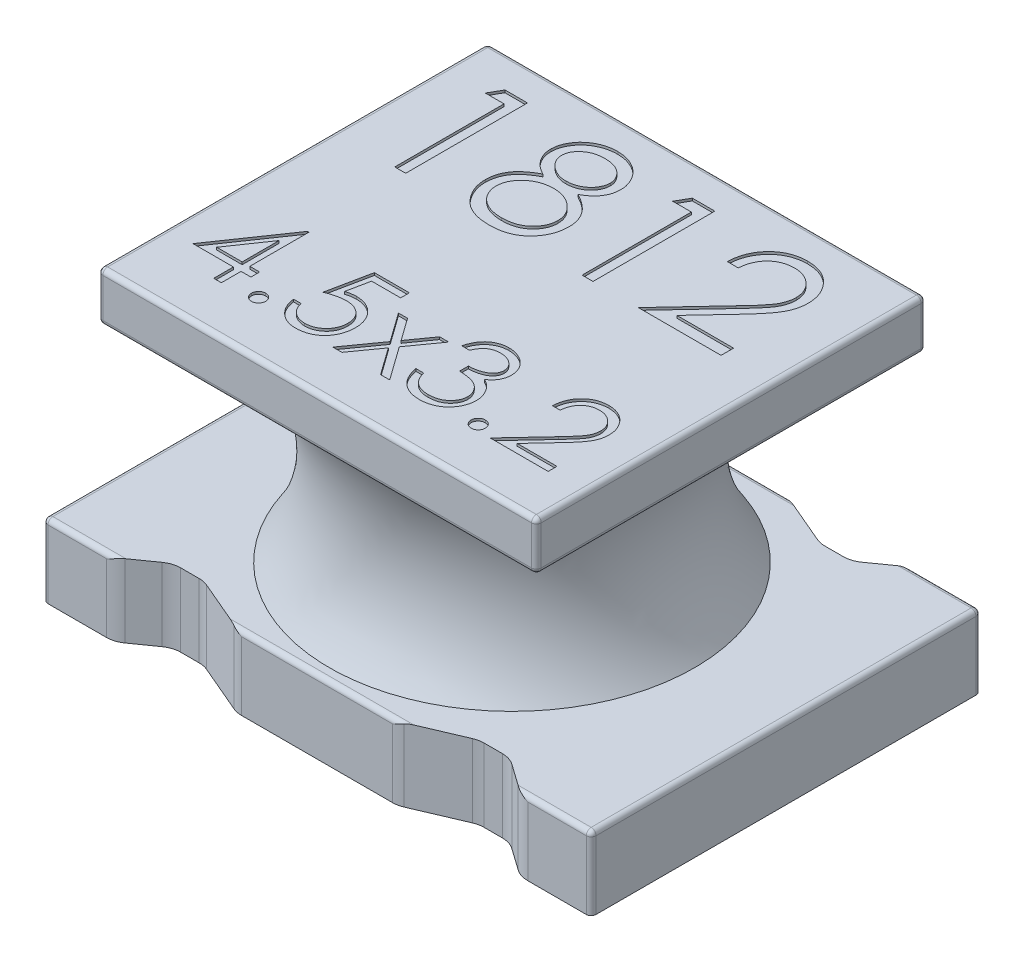
from build123d import *

# Parameters (mm, degrees)
SKETCH1_W           = 4.5
SKETCH1_H           = 3.2
BOSS_EXTRUDE1_DEPTH = 2.6
SKETCH4_W           = 1
SKETCH4_H           = 3.5
CUT_EXTRUDE2_DEPTH  = 1.5
FILLET1_R           = 0.04
CUT_EXTRUDE3_DEPTH  = 1
CUT_EXTRUDE4_DEPTH  = 0.02
CUT_EXTRUDE5_DEPTH  = 0.02


with BuildPart() as part:
    # Sketch1 → Boss-Extrude1 (new body)
    with BuildSketch(Plane(origin=(0, 0, 0), x_dir=(1, 0, 0), z_dir=(0, 1, 0))):
        Rectangle(SKETCH1_W, SKETCH1_H)
    extrude(amount=BOSS_EXTRUDE1_DEPTH)

    # Sketch3 → Cut-Revolve1 (revolve, cut)
    with BuildSketch(Plane(origin=(0, 0, 0), x_dir=(0, 0, -1), z_dir=(1, 0, 0))):
        with BuildLine():
            Line((3.2, 2.2), (3.2, 0.6))
            Line((3.2, 0.6), (1.5, 0.6))
            ThreePointArc((1.5, 0.6), (1.248912529, 1.4), (1.5, 2.2))
            Line((1.5, 2.2), (3.2, 2.2))
        make_face()
    revolve(axis=Axis((0, 0, 0), (0, 1, 0)), mode=Mode.SUBTRACT)

    # Sketch4 → Cut-Extrude2 (cut)
    with BuildSketch(Plane(origin=(0, 2.6, 0), x_dir=(1, 0, 0), z_dir=(0, 1, 0))):
        with Locations((2.3, 0)):
            Rectangle(SKETCH4_W, SKETCH4_H)
        with Locations((-2.3, 0)):
            Rectangle(SKETCH4_W, SKETCH4_H)
    extrude(amount=-CUT_EXTRUDE2_DEPTH, mode=Mode.SUBTRACT)

    # Fillet1
    fillet1_edges = [part.edges().sort_by_distance(p)[0] for p in [
        (-2.25, 0.3, -1.6),
        (2.25, 0.3, -1.6),
        (0, 0.6, -1.6),
        (2.25, 0.3, 1.6),
        (-2.25, 0.3, 1.6),
        (0, 0.6, 1.6),
        (-2.25, 0.6, 0),
        (2.25, 0.6, 0),
        (0, 2.2, -1.6),
        (1.8, 2.2, 0),
        (0, 2.6, -1.6),
        (1.8, 2.6, 0),
        (1.8, 2.4, 1.6),
        (1.8, 2.4, -1.6),
        (0, 2.2, 1.6),
        (-1.8, 2.2, 0),
        (0, 2.6, 1.6),
        (-1.8, 2.6, 0),
        (-1.8, 2.4, 1.6),
        (-1.8, 2.4, -1.6),
    ]]
    fillet(fillet1_edges, radius=FILLET1_R)

    # Sketch5 → Cut-Extrude3 (cut)
    with BuildSketch(Plane.XZ):
        with BuildLine():
            Line((-1.614539572, 1.563306122), (-1.435460428, 1.436693878))
            ThreePointArc((-1.435460428, 1.436693878), (-1.380575472, 1.409394092), (-1.32, 1.4))
            Line((-1.32, 1.4), (-1.17, 1.4))
            ThreePointArc((-1.17, 1.4), (-1.129898015, 1.404061666), (-1.091424839, 1.416081692))
            Line((-1.091424839, 1.416081692), (-0.698575161, 1.583918308))
            ThreePointArc((-0.698575161, 1.583918308), (-0.660101985, 1.595938334), (-0.62, 1.6))
            Line((-0.62, 1.6), (-0.5, 1.6))
            Line((-0.5, 1.6), (-0.5, 1.9))
            Line((-0.5, 1.9), (-1.85, 1.9))
            Line((-1.85, 1.9), (-1.85, 1.6))
            Line((-1.85, 1.6), (-1.73, 1.6))
            ThreePointArc((-1.73, 1.6), (-1.669424528, 1.590605908), (-1.614539572, 1.563306122))
        make_face()
        with BuildLine():
            Line((-0.5, -1.6), (-0.62, -1.6))
            ThreePointArc((-0.62, -1.6), (-0.660101985, -1.595938334), (-0.698575161, -1.583918308))
            Line((-0.698575161, -1.583918308), (-1.091424839, -1.416081692))
            ThreePointArc((-1.091424839, -1.416081692), (-1.129898015, -1.404061666), (-1.17, -1.4))
            Line((-1.17, -1.4), (-1.32, -1.4))
            ThreePointArc((-1.32, -1.4), (-1.380575472, -1.409394092), (-1.435460428, -1.436693878))
            Line((-1.435460428, -1.436693878), (-1.614539572, -1.563306122))
            ThreePointArc((-1.614539572, -1.563306122), (-1.669424528, -1.590605908), (-1.73, -1.6))
            Line((-1.73, -1.6), (-1.85, -1.6))
            Line((-1.85, -1.6), (-1.85, -1.9))
            Line((-1.85, -1.9), (-0.5, -1.9))
            Line((-0.5, -1.9), (-0.5, -1.6))
        make_face()
        with BuildLine():
            Line((1.614539572, -1.563306122), (1.435460428, -1.436693878))
            ThreePointArc((1.435460428, -1.436693878), (1.380575472, -1.409394092), (1.32, -1.4))
            Line((1.32, -1.4), (1.17, -1.4))
            ThreePointArc((1.17, -1.4), (1.129898015, -1.404061666), (1.091424839, -1.416081692))
            Line((1.091424839, -1.416081692), (0.698575161, -1.583918308))
            ThreePointArc((0.698575161, -1.583918308), (0.660101985, -1.595938334), (0.62, -1.6))
            Line((0.62, -1.6), (0.5, -1.6))
            Line((0.5, -1.6), (0.5, -1.9))
            Line((0.5, -1.9), (1.85, -1.9))
            Line((1.85, -1.9), (1.85, -1.6))
            Line((1.85, -1.6), (1.73, -1.6))
            ThreePointArc((1.73, -1.6), (1.669424528, -1.590605908), (1.614539572, -1.563306122))
        make_face()
        with BuildLine():
            Line((0.5, 1.6), (0.62, 1.6))
            ThreePointArc((0.62, 1.6), (0.660101985, 1.595938334), (0.698575161, 1.583918308))
            Line((0.698575161, 1.583918308), (1.091424839, 1.416081692))
            ThreePointArc((1.091424839, 1.416081692), (1.129898015, 1.404061666), (1.17, 1.4))
            Line((1.17, 1.4), (1.32, 1.4))
            ThreePointArc((1.32, 1.4), (1.380575472, 1.409394092), (1.435460428, 1.436693878))
            Line((1.435460428, 1.436693878), (1.614539572, 1.563306122))
            ThreePointArc((1.614539572, 1.563306122), (1.669424528, 1.590605908), (1.73, 1.6))
            Line((1.73, 1.6), (1.85, 1.6))
            Line((1.85, 1.6), (1.85, 1.9))
            Line((1.85, 1.9), (0.5, 1.9))
            Line((0.5, 1.9), (0.5, 1.6))
        make_face()
    extrude(amount=-CUT_EXTRUDE3_DEPTH, mode=Mode.SUBTRACT)

    # Sketch6 → Cut-Extrude4 (cut)
    with BuildSketch(Plane(origin=(0, 2.6, 0), x_dir=(1, 0, 0), z_dir=(0, 1, 0))):
        Polygon((-1.387573864, 1.32963938), (-1.202678031, 1.32963938), (-1.202678031, 0.32963938), (-1.29242162, 0.32963938), (-1.29242162, 1.227075277), (-1.446267774, 1.227075277), align=None)
        with BuildLine():
            add(Edge.make_bspline(
                [(-0.344705274, 0.886730726), (-0.336519975, 0.882462738), (-0.320555908, 0.874138738), (-0.297819563, 0.860735644), (-0.277040991, 0.846609654), (-0.257643688, 0.83242798), (-0.239968445, 0.817647508), (-0.224212898, 0.802209463), (-0.209987864, 0.786499193), (-0.197580211, 0.770250668), (-0.186666829, 0.753507054), (-0.177234791, 0.736224404), (-0.169172733, 0.718440595), (-0.162783322, 0.6999615), (-0.157519953, 0.681058568), (-0.153898351, 0.661487716), (-0.15195066, 0.641377905), (-0.151582428, 0.627786961), (-0.151395979, 0.620905405)],
                knots=[0, 0, 0, 0, 1.272397273, 2.481599622, 3.635517121, 4.734568067, 5.792894095, 6.808321871, 7.773003508, 8.711915296, 9.623354172, 10.525449501, 11.423591555, 12.311487226, 13.218079475, 14.126165749, 15.051214107, 16, 16, 16, 16], degree=3))
            add(Edge.make_bspline(
                [(-0.151395979, 0.620905405), (-0.151616385, 0.611277482), (-0.152052651, 0.592220208), (-0.155852647, 0.564092748), (-0.161542069, 0.536775096), (-0.169850501, 0.510273241), (-0.180625756, 0.484733421), (-0.193904852, 0.460133771), (-0.208936625, 0.436071111), (-0.221008693, 0.421265568), (-0.227117133, 0.413773995)],
                knots=[0, 0, 0, 0, 1.025265484, 2.029385089, 3.018602448, 3.995076438, 4.983346944, 5.966715145, 6.97116228, 8, 8, 8, 8], degree=3))
            add(Edge.make_bspline(
                [(-0.227117133, 0.413773995), (-0.235070412, 0.405032917), (-0.250878688, 0.387658776), (-0.277959524, 0.365101402), (-0.307680062, 0.346144432), (-0.3399253, 0.330695319), (-0.374609043, 0.318670788), (-0.411723902, 0.310030069), (-0.451342231, 0.305080803), (-0.478572366, 0.304365378), (-0.492541813, 0.303998354)],
                knots=[0, 0, 0, 0, 0.954267603, 1.896743057, 2.838368354, 3.796610408, 4.779680527, 5.799409237, 6.871065594, 8, 8, 8, 8], degree=3))
            add(Edge.make_bspline(
                [(-0.492541813, 0.303998354), (-0.505974209, 0.304327634), (-0.532112289, 0.304968378), (-0.570157397, 0.309309644), (-0.605621131, 0.316917606), (-0.638709694, 0.327330351), (-0.669223606, 0.340876131), (-0.697075921, 0.357735676), (-0.722668484, 0.377230374), (-0.745224619, 0.399920111), (-0.765249889, 0.42422236), (-0.782840761, 0.449294248), (-0.797461927, 0.475138065), (-0.809841097, 0.501368455), (-0.819317675, 0.528353071), (-0.825881163, 0.555953075), (-0.830049539, 0.584120258), (-0.830604149, 0.603129302), (-0.830883159, 0.612692264)],
                knots=[0, 0, 0, 0, 1.256902934, 2.445805442, 3.576955095, 4.645999104, 5.686449165, 6.692658513, 7.68621702, 8.689161843, 9.678783111, 10.630372946, 11.551080876, 12.453998257, 13.34127905, 14.221779781, 15.105423033, 16, 16, 16, 16], degree=3))
            add(Edge.make_bspline(
                [(-0.830883159, 0.612692264), (-0.83071805, 0.619709176), (-0.830391737, 0.633577071), (-0.828133209, 0.654065451), (-0.82450222, 0.674007203), (-0.819570946, 0.693475987), (-0.812887796, 0.712330065), (-0.804818615, 0.730658772), (-0.795409486, 0.7484828), (-0.784529153, 0.765899623), (-0.771871432, 0.782665198), (-0.75753896, 0.799064054), (-0.741245284, 0.81484173), (-0.723171667, 0.830190995), (-0.703524655, 0.84538413), (-0.681793932, 0.859600052), (-0.65855557, 0.873845185), (-0.64203974, 0.88236185), (-0.633567454, 0.886730726)],
                knots=[0, 0, 0, 0, 0.941657376, 1.861047343, 2.762797495, 3.66048619, 4.553285746, 5.444104102, 6.34607688, 7.256116206, 8.197091036, 9.162375105, 10.176350973, 11.237807142, 12.343728897, 13.50695164, 14.721116704, 16, 16, 16, 16], degree=3))
            add(Edge.make_bspline(
                [(-0.633567454, 0.886730726), (-0.645164989, 0.893054945), (-0.667621064, 0.905300405), (-0.697355191, 0.927799492), (-0.722895369, 0.952167439), (-0.743539574, 0.978918809), (-0.759788782, 1.007217916), (-0.770936954, 1.036887703), (-0.778478807, 1.067378021), (-0.7792259, 1.088208363), (-0.779601108, 1.098669828)],
                knots=[0, 0, 0, 0, 1.166880483, 2.259407225, 3.286803203, 4.280235371, 5.237608625, 6.161067461, 7.076446754, 8, 8, 8, 8], degree=3))
            add(Edge.make_bspline(
                [(-0.779601108, 1.098669828), (-0.779133844, 1.109326274), (-0.778194561, 1.130747587), (-0.770599327, 1.162635051), (-0.758222165, 1.193954069), (-0.741387595, 1.224552845), (-0.720419818, 1.253395763), (-0.695263663, 1.279264605), (-0.666519863, 1.301925028), (-0.634331901, 1.320946792), (-0.599692977, 1.336427837), (-0.563145627, 1.347107387), (-0.525326629, 1.354089134), (-0.499584424, 1.354879607), (-0.486532197, 1.355280405)],
                knots=[0, 0, 0, 0, 0.888701115, 1.786444228, 2.72001202, 3.692817113, 4.693886446, 5.687152267, 6.695133018, 7.739871481, 8.800368666, 9.853104506, 10.91144658, 12, 12, 12, 12], degree=3))
            add(Edge.make_bspline(
                [(-0.486532197, 1.355280405), (-0.473816822, 1.354867164), (-0.448743549, 1.354052301), (-0.411887941, 1.34725605), (-0.376623691, 1.335904758), (-0.343072405, 1.320505552), (-0.311834729, 1.301537854), (-0.284234069, 1.278566176), (-0.259853331, 1.252811447), (-0.239686362, 1.223977275), (-0.223068393, 1.193496077), (-0.211496707, 1.161603928), (-0.204081857, 1.128989911), (-0.203146611, 1.10692191), (-0.202678031, 1.095865341)],
                knots=[0, 0, 0, 0, 1.072916533, 2.115669174, 3.151510826, 4.193348718, 5.225979165, 6.227137561, 7.216255879, 8.211077061, 9.189680878, 10.138522389, 11.067357538, 12, 12, 12, 12], degree=3))
            add(Edge.make_bspline(
                [(-0.202678031, 1.095865341), (-0.203087905, 1.085014866), (-0.203892875, 1.063705149), (-0.210664287, 1.032640429), (-0.22206809, 1.003548418), (-0.237637851, 0.976099003), (-0.257930848, 0.950790003), (-0.2826762, 0.927299583), (-0.311676622, 0.905434775), (-0.333465447, 0.893095814), (-0.344705274, 0.886730726)],
                knots=[0, 0, 0, 0, 0.975232327, 1.915300861, 2.843280834, 3.77672583, 4.742871857, 5.749627742, 6.839139064, 8, 8, 8, 8], degree=3))
        make_face()
        with BuildLine():
            add(Edge.make_bspline(
                [(-0.49154021, 1.252716303), (-0.498554726, 1.252530177), (-0.512278186, 1.252166033), (-0.532400664, 1.250263566), (-0.551535626, 1.246562647), (-0.569882998, 1.2416373), (-0.58719123, 1.234983589), (-0.603695388, 1.227156444), (-0.619114585, 1.217640425), (-0.633634958, 1.206965797), (-0.646706607, 1.195224967), (-0.658307908, 1.182992476), (-0.667944512, 1.170028078), (-0.676127686, 1.156654261), (-0.682065262, 1.142474096), (-0.686512206, 1.127922332), (-0.689518318, 1.112815079), (-0.689743573, 1.102490362), (-0.689857518, 1.097267585)],
                knots=[0, 0, 0, 0, 1.203892937, 2.355340988, 3.463153438, 4.544400666, 5.610487187, 6.640501085, 7.674077295, 8.714426146, 9.728707835, 10.68524104, 11.601827946, 12.495867327, 13.368432065, 14.231010473, 15.105153427, 16, 16, 16, 16], degree=3))
            add(Edge.make_bspline(
                [(-0.689857518, 1.097267585), (-0.689661127, 1.092044582), (-0.689273031, 1.081723178), (-0.686271566, 1.066481502), (-0.681798179, 1.051503892), (-0.674755133, 1.037146489), (-0.666307602, 1.022911243), (-0.655881466, 1.009153933), (-0.64345603, 0.99582668), (-0.629448189, 0.98304284), (-0.61418775, 0.971071765), (-0.598020881, 0.960679427), (-0.581150483, 0.951983967), (-0.563749892, 0.944746994), (-0.545641764, 0.939121298), (-0.526937057, 0.935130256), (-0.507632628, 0.932649685), (-0.494552462, 0.932353394), (-0.487934441, 0.932203482)],
                knots=[0, 0, 0, 0, 0.873023192, 1.725219244, 2.590779336, 3.480155217, 4.391973325, 5.357036234, 6.360879153, 7.436073238, 8.526419356, 9.601555421, 10.645666583, 11.697338044, 12.750135903, 13.812665442, 14.89329948, 16, 16, 16, 16], degree=3))
            add(Edge.make_bspline(
                [(-0.487934441, 0.932203482), (-0.479434411, 0.932452873), (-0.462518306, 0.932949191), (-0.437581354, 0.937563812), (-0.413334885, 0.944822646), (-0.390038055, 0.954754065), (-0.368293887, 0.967219167), (-0.348911011, 0.982142887), (-0.332054756, 0.999180629), (-0.317900296, 1.018067153), (-0.306926054, 1.038167607), (-0.29838268, 1.058339119), (-0.293393762, 1.0787969), (-0.292743028, 1.092501746), (-0.29242162, 1.09927079)],
                knots=[0, 0, 0, 0, 1.076279235, 2.141928126, 3.20205304, 4.278698113, 5.344010996, 6.36967002, 7.368914609, 8.37248503, 9.349703398, 10.264243087, 11.142681841, 12, 12, 12, 12], degree=3))
            add(Edge.make_bspline(
                [(-0.29242162, 1.09927079), (-0.292573591, 1.104021657), (-0.292875231, 1.113451448), (-0.295360962, 1.127376695), (-0.299468342, 1.140985148), (-0.305029222, 1.154389225), (-0.312346307, 1.167400863), (-0.321021789, 1.180224602), (-0.331560218, 1.192571964), (-0.34338777, 1.204730692), (-0.356800744, 1.21598327), (-0.37177329, 1.225878901), (-0.388228648, 1.234282432), (-0.406167205, 1.24110779), (-0.425522897, 1.246234176), (-0.446206576, 1.250073132), (-0.468390704, 1.252236879), (-0.483656347, 1.252553029), (-0.49154021, 1.252716303)],
                knots=[0, 0, 0, 0, 0.814439003, 1.616544685, 2.417341072, 3.248991801, 4.09997495, 4.973547432, 5.9003056, 6.880240646, 7.880314356, 8.896779544, 9.951930927, 11.043077905, 12.18215768, 13.381699519, 14.647792085, 16, 16, 16, 16], degree=3))
        make_face(mode=Mode.SUBTRACT)
        with BuildLine():
            add(Edge.make_bspline(
                [(-0.485730915, 0.82963938), (-0.494623997, 0.829481196), (-0.512070053, 0.82917088), (-0.537629175, 0.825716737), (-0.562158651, 0.820908339), (-0.585575776, 0.813613813), (-0.607870661, 0.804129102), (-0.629163999, 0.792719233), (-0.649292893, 0.779231964), (-0.667979386, 0.763838645), (-0.685043194, 0.74725023), (-0.700014137, 0.72968962), (-0.712727715, 0.711483182), (-0.722965786, 0.692399688), (-0.731369138, 0.672843227), (-0.736887389, 0.652326771), (-0.740425021, 0.631244739), (-0.740900058, 0.616913282), (-0.741139569, 0.609687457)],
                knots=[0, 0, 0, 0, 1.140299081, 2.23698856, 3.303958914, 4.344563908, 5.37730929, 6.408454204, 7.439741482, 8.480804886, 9.510774543, 10.48932336, 11.43758569, 12.353841022, 13.263987381, 14.161954604, 15.073269652, 16, 16, 16, 16], degree=3))
            add(Edge.make_bspline(
                [(-0.741139569, 0.609687457), (-0.740750067, 0.600707198), (-0.739977303, 0.582890574), (-0.733846835, 0.556558268), (-0.72400811, 0.531066538), (-0.71028662, 0.506623123), (-0.693295885, 0.483780235), (-0.672402608, 0.463869157), (-0.648905226, 0.446177306), (-0.622008696, 0.431868582), (-0.592629135, 0.42044148), (-0.560774355, 0.412568348), (-0.526901521, 0.407356505), (-0.503513066, 0.406831311), (-0.49154021, 0.406562457)],
                knots=[0, 0, 0, 0, 0.898778495, 1.783155532, 2.693654817, 3.627872908, 4.583023416, 5.533784346, 6.509005473, 7.520592997, 8.575161974, 9.658835044, 10.801527049, 12, 12, 12, 12], degree=3))
            add(Edge.make_bspline(
                [(-0.49154021, 0.406562457), (-0.482182962, 0.406742116), (-0.463952043, 0.407092151), (-0.437356057, 0.410181949), (-0.412257615, 0.415081842), (-0.388705387, 0.422208569), (-0.366435718, 0.430908562), (-0.345826188, 0.442100586), (-0.326346609, 0.454829821), (-0.30895686, 0.469932151), (-0.2931188, 0.48606915), (-0.279309288, 0.503152019), (-0.267321416, 0.520716486), (-0.257912572, 0.539159481), (-0.250390785, 0.558127171), (-0.244984055, 0.57779446), (-0.241647993, 0.598221669), (-0.241310595, 0.612078547), (-0.241139569, 0.619102521)],
                knots=[0, 0, 0, 0, 1.224942928, 2.386581632, 3.501229538, 4.569074225, 5.605009692, 6.626002462, 7.634866581, 8.645888296, 9.63523824, 10.59253846, 11.518950513, 12.414518923, 13.29783783, 14.186679152, 15.080837789, 16, 16, 16, 16], degree=3))
            add(Edge.make_bspline(
                [(-0.241139569, 0.619102521), (-0.241398383, 0.625924618), (-0.241908719, 0.639376602), (-0.245147773, 0.659309896), (-0.250838024, 0.678567843), (-0.258645852, 0.69738213), (-0.269040412, 0.715371544), (-0.281281804, 0.733004736), (-0.296051552, 0.749792292), (-0.312740865, 0.765864605), (-0.33092914, 0.780726244), (-0.35026261, 0.793873226), (-0.370592456, 0.80494526), (-0.391875659, 0.813949973), (-0.414064961, 0.821032107), (-0.43714404, 0.825979534), (-0.461139919, 0.829093706), (-0.477441311, 0.829455434), (-0.485730915, 0.82963938)],
                knots=[0, 0, 0, 0, 0.917430815, 1.809013306, 2.70690318, 3.612392954, 4.541220862, 5.495268465, 6.494511384, 7.542276156, 8.608045339, 9.649016899, 10.681629292, 11.715607085, 12.752076957, 13.808767841, 14.885711793, 16, 16, 16, 16], degree=3))
        make_face(mode=Mode.SUBTRACT)
        Polygon((0.150887674, 1.32963938), (0.335783508, 1.32963938), (0.335783508, 0.32963938), (0.246039918, 0.32963938), (0.246039918, 1.227075277), (0.092193764, 1.227075277), align=None)
        with BuildLine():
            Line((0.835783508, 1.021947072), (0.746039918, 1.021947072))
            add(Edge.make_bspline(
                [(0.746039918, 1.021947072), (0.746624819, 1.03385304), (0.747773549, 1.057236044), (0.75315306, 1.091328589), (0.760850453, 1.123915674), (0.771733726, 1.15473565), (0.785249805, 1.184061023), (0.801458385, 1.211775313), (0.820656628, 1.237772796), (0.84242998, 1.261812465), (0.866078163, 1.283866057), (0.891594145, 1.302910412), (0.91840701, 1.319001175), (0.94643541, 1.332452959), (0.975995571, 1.342550057), (1.006819245, 1.350041955), (1.039041855, 1.354549482), (1.060996147, 1.355033992), (1.072161713, 1.355280405)],
                knots=[0, 0, 0, 0, 1.10065271, 2.161652631, 3.183658789, 4.190468796, 5.17591951, 6.163126047, 7.15150782, 8.156236427, 9.156009102, 10.134482811, 11.092018607, 12.041330605, 13.001268258, 13.972401359, 14.968799086, 16, 16, 16, 16], degree=3))
            add(Edge.make_bspline(
                [(1.072161713, 1.355280405), (1.083126877, 1.355023704), (1.104673033, 1.354519294), (1.136119322, 1.350187571), (1.166055692, 1.343403116), (1.194423626, 1.333884426), (1.220996787, 1.321088875), (1.2459748, 1.30571815), (1.269655031, 1.287941055), (1.290971255, 1.267011394), (1.310544992, 1.244667856), (1.327431351, 1.220814169), (1.341892254, 1.19617723), (1.353945877, 1.170569173), (1.36281906, 1.143748879), (1.369555691, 1.116106821), (1.373363523, 1.087356875), (1.37394793, 1.067897859), (1.374245046, 1.058004764)],
                knots=[0, 0, 0, 0, 1.111607364, 2.184268762, 3.212621178, 4.221274766, 5.211760367, 6.196651075, 7.1921475, 8.207485113, 9.220403448, 10.201281604, 11.166441695, 12.114753415, 13.065576456, 14.026450734, 14.996634279, 16, 16, 16, 16], degree=3))
            add(Edge.make_bspline(
                [(1.374245046, 1.058004764), (1.373761257, 1.044076812), (1.372802168, 1.016465322), (1.36459806, 0.975889647), (1.351784771, 0.936577241), (1.336356955, 0.904938012), (1.3207934, 0.879442728), (1.306768398, 0.85845167), (1.29034988, 0.835850107), (1.271298881, 0.811713725), (1.250009489, 0.785853467), (1.226288871, 0.758284954), (1.199967876, 0.72929302), (1.181494018, 0.709491419), (1.171921328, 0.699230726)],
                knots=[0, 0, 0, 0, 1.184426356, 2.348067706, 3.509069118, 4.696110526, 5.333549288, 6.050745305, 6.844228056, 7.710549037, 8.667450064, 9.695053472, 10.805634456, 12, 12, 12, 12], degree=3))
            Line((1.171921328, 0.699230726), (0.921721008, 0.432203482))
            Line((0.921721008, 0.432203482), (1.387065559, 0.432203482))
            Line((1.387065559, 0.432203482), (1.387065559, 0.32963938))
            Line((1.387065559, 0.32963938), (0.70757838, 0.32963938))
            Line((0.70757838, 0.32963938), (1.095398892, 0.743501559))
            add(Edge.make_bspline(
                [(1.095398892, 0.743501559), (1.104841146, 0.753358218), (1.122977782, 0.772290843), (1.148629947, 0.799931689), (1.171669658, 0.825574415), (1.192246056, 0.849170571), (1.209912772, 0.871065305), (1.225590552, 0.890549506), (1.23815215, 0.908479349), (1.25178512, 0.929262382), (1.264989114, 0.954637329), (1.276335502, 0.985646955), (1.28325403, 1.017569027), (1.284083983, 1.039141038), (1.284501456, 1.049991944)],
                knots=[0, 0, 0, 0, 1.329631726, 2.553950428, 3.673215718, 4.687767853, 5.603093632, 6.413772471, 7.123043292, 7.734684054, 8.834405432, 9.900288307, 10.943827018, 12, 12, 12, 12], degree=3))
            add(Edge.make_bspline(
                [(1.284501456, 1.049991944), (1.284319816, 1.056815201), (1.283961837, 1.070262529), (1.280802495, 1.08997846), (1.276028065, 1.108996979), (1.269186562, 1.127376584), (1.260156065, 1.144932485), (1.249163671, 1.16168605), (1.236480796, 1.177882898), (1.221809004, 1.193069554), (1.205691427, 1.20697847), (1.188664499, 1.219299637), (1.170650183, 1.229596526), (1.151724434, 1.238037525), (1.131940014, 1.244659063), (1.111258658, 1.249247228), (1.089737511, 1.252127938), (1.075042226, 1.252517701), (1.067554341, 1.252716303)],
                knots=[0, 0, 0, 0, 0.991446411, 1.95395049, 2.89581595, 3.838931463, 4.798493298, 5.75982156, 6.748411868, 7.785213223, 8.824556874, 9.840280684, 10.836137867, 11.835679398, 12.848801643, 13.863922112, 14.911575587, 16, 16, 16, 16], degree=3))
            add(Edge.make_bspline(
                [(1.067554341, 1.252716303), (1.059734103, 1.252512008), (1.044376447, 1.252110806), (1.021828152, 1.249304331), (1.00031793, 1.244462662), (0.979791672, 1.237840755), (0.960214647, 1.229424027), (0.941682063, 1.218940671), (0.924235524, 1.206431102), (0.907842231, 1.192248086), (0.892738237, 1.176457343), (0.879467701, 1.158854496), (0.867872269, 1.139760949), (0.857755345, 1.11922822), (0.849539433, 1.097069997), (0.84326139, 1.073364939), (0.83829372, 1.048215973), (0.836634142, 1.030848805), (0.835783508, 1.021947072)],
                knots=[0, 0, 0, 0, 1.031018746, 2.02475058, 2.990194455, 3.934040569, 4.864654155, 5.795059489, 6.735614925, 7.690564532, 8.649604399, 9.611025574, 10.590972636, 11.591080095, 12.624614302, 13.701020113, 14.821632451, 16, 16, 16, 16], degree=3))
        make_face()
    extrude(amount=-CUT_EXTRUDE4_DEPTH, mode=Mode.SUBTRACT)

    # Sketch7 → Cut-Extrude5 (cut)
    with BuildSketch(Plane(origin=(0, 2.6, 0), x_dir=(1, 0, 0), z_dir=(0, 1, 0))):
        Polygon((-1.193674007, -0.487519703), (-1.18091359, -0.487519703), (-1.18091359, -0.972135088), (-1.100144359, -0.972135088), (-1.100144359, -1.043929959), (-1.18091359, -1.043929959), (-1.18091359, -1.205468421), (-1.243734103, -1.205468421), (-1.243734103, -1.043929959), (-1.575785385, -1.043929959), align=None)
        Polygon((-1.243734103, -0.972135088), (-1.243734103, -0.668128677), (-1.452387949, -0.972135088), align=None, mode=Mode.SUBTRACT)
        with BuildLine():
            add(Edge.make_bspline(
                [(-0.925144359, -1.097776113), (-0.921246317, -1.098007747), (-0.91360466, -1.098461837), (-0.902556835, -1.101577171), (-0.892557903, -1.107108904), (-0.883651454, -1.114481459), (-0.876310159, -1.123420592), (-0.870581288, -1.133339774), (-0.867493091, -1.144480092), (-0.867042309, -1.152166027), (-0.866811026, -1.156109447)],
                knots=[0, 0, 0, 0, 1.020151414, 1.999887582, 2.974338812, 3.990962822, 5.007586832, 5.987933904, 6.967670073, 8, 8, 8, 8], degree=3))
            add(Edge.make_bspline(
                [(-0.866811026, -1.156109447), (-0.867050146, -1.159958113), (-0.867521688, -1.167547625), (-0.870574209, -1.178603918), (-0.876353819, -1.188529299), (-0.883600818, -1.197589726), (-0.892560105, -1.2049779), (-0.902580474, -1.210462569), (-0.913578725, -1.213800965), (-0.92124199, -1.214226225), (-0.925144359, -1.21444278)],
                knots=[0, 0, 0, 0, 1.009421747, 1.99056486, 2.972319754, 3.999869655, 5.017953583, 5.993804169, 6.978383603, 8, 8, 8, 8], degree=3))
            add(Edge.make_bspline(
                [(-0.925144359, -1.21444278), (-0.92904954, -1.214234061), (-0.936673477, -1.213826586), (-0.947630676, -1.210394024), (-0.95771207, -1.205029332), (-0.966669612, -1.19757595), (-0.973977306, -1.188575922), (-0.979502383, -1.178535562), (-0.982820413, -1.167579275), (-0.983256787, -1.159964346), (-0.983477693, -1.156109447)],
                knots=[0, 0, 0, 0, 1.022052826, 1.995314843, 2.982371812, 4.00089066, 5.028879526, 6.005146991, 6.990147033, 8, 8, 8, 8], degree=3))
            add(Edge.make_bspline(
                [(-0.983477693, -1.156109447), (-0.983265273, -1.152159571), (-0.982850549, -1.144447923), (-0.979495417, -1.133408101), (-0.974020175, -1.123374413), (-0.966619096, -1.114495097), (-0.957714237, -1.107057637), (-0.947654995, -1.101644678), (-0.936647087, -1.098436596), (-0.9290451, -1.098000092), (-0.925144359, -1.097776113)],
                knots=[0, 0, 0, 0, 1.032775665, 2.016367738, 2.991239715, 4.008302682, 5.025365648, 6.011011707, 6.979408107, 8, 8, 8, 8], degree=3))
        make_face()
        with BuildLine():
            Line((-0.337323847, -0.505468421), (-0.337323847, -0.577263293))
            Line((-0.337323847, -0.577263293), (-0.575424808, -0.577263293))
            Line((-0.575424808, -0.577263293), (-0.613145161, -0.761377876))
            add(Edge.make_bspline(
                [(-0.613145161, -0.761377876), (-0.605733986, -0.759331822), (-0.591376007, -0.755367915), (-0.570184034, -0.750966761), (-0.550065594, -0.748313672), (-0.53701052, -0.74795141), (-0.530693238, -0.747776113)],
                knots=[0, 0, 0, 0, 1.100273476, 2.13160584, 3.095893838, 4, 4, 4, 4], degree=3))
            add(Edge.make_bspline(
                [(-0.530693238, -0.747776113), (-0.52287649, -0.7479453), (-0.50750681, -0.748277965), (-0.485019021, -0.751472335), (-0.463552442, -0.756500317), (-0.443151968, -0.763524422), (-0.423779858, -0.772506368), (-0.405614346, -0.783726356), (-0.388382763, -0.796833023), (-0.372394244, -0.811902025), (-0.357889383, -0.828486348), (-0.345136185, -0.846317923), (-0.334303667, -0.865223455), (-0.325591516, -0.885383577), (-0.318634649, -0.906575408), (-0.31400425, -0.929021924), (-0.310920908, -0.952511548), (-0.310576431, -0.968572462), (-0.31040077, -0.976762491)],
                knots=[0, 0, 0, 0, 1.052922333, 2.070308379, 3.05430497, 4.020497103, 4.973039431, 5.925935799, 6.892292201, 7.88610001, 8.88166317, 9.857072816, 10.836096531, 11.812156883, 12.81219415, 13.836441305, 14.89672472, 16, 16, 16, 16], degree=3))
            add(Edge.make_bspline(
                [(-0.31040077, -0.976762491), (-0.310533785, -0.982466936), (-0.310798017, -0.993798733), (-0.312141735, -1.010627573), (-0.314728878, -1.02710014), (-0.318202423, -1.043218618), (-0.322710906, -1.058952493), (-0.328168717, -1.074346798), (-0.334847923, -1.08930572), (-0.342174198, -1.103970799), (-0.350423493, -1.1180105), (-0.359579195, -1.131140297), (-0.369252293, -1.143557154), (-0.37966057, -1.1551279), (-0.390900769, -1.165776504), (-0.402836762, -1.17556616), (-0.415373306, -1.184662426), (-0.428704355, -1.192696065), (-0.442532851, -1.200088656), (-0.457058495, -1.206153364), (-0.471950635, -1.21157547), (-0.48742361, -1.215897375), (-0.503442372, -1.219283886), (-0.520033328, -1.221584006), (-0.537109462, -1.223259294), (-0.548684464, -1.223364165), (-0.554531379, -1.223417139)],
                knots=[0, 0, 0, 0, 1.056347294, 2.098418968, 3.122841568, 4.141288669, 5.149314143, 6.15115421, 7.162517403, 8.180376062, 9.185164535, 10.17417709, 11.141909838, 12.097768115, 13.052685741, 14.0056014, 14.954263652, 15.917497458, 16.885230207, 17.854509472, 18.828990115, 19.81800267, 20.826176721, 21.857883937, 22.917946725, 24, 24, 24, 24], degree=3))
            add(Edge.make_bspline(
                [(-0.554531379, -1.223417139), (-0.561506215, -1.223278971), (-0.575228381, -1.223007143), (-0.595332494, -1.220163446), (-0.614675415, -1.216090663), (-0.633101436, -1.209963409), (-0.650775688, -1.20228595), (-0.667460232, -1.192582715), (-0.683581387, -1.181586895), (-0.698483794, -1.168610824), (-0.712315017, -1.154427688), (-0.724696319, -1.139036159), (-0.735723034, -1.122690271), (-0.745218584, -1.10531064), (-0.753318188, -1.086942934), (-0.759681186, -1.067518334), (-0.764816857, -1.047138333), (-0.766989541, -1.033107631), (-0.768093077, -1.025981241)],
                knots=[0, 0, 0, 0, 1.0467383, 2.05933395, 3.04377827, 4.011590433, 4.970194871, 5.932262533, 6.905835911, 7.896367577, 8.894135286, 9.877477877, 10.858688626, 11.851381753, 12.8477658, 13.868841284, 14.917554742, 16, 16, 16, 16], degree=3))
            Line((-0.768093077, -1.025981241), (-0.705272564, -1.025981241))
            add(Edge.make_bspline(
                [(-0.705272564, -1.025981241), (-0.703726853, -1.032656532), (-0.70075591, -1.045486811), (-0.69423476, -1.063513079), (-0.686261585, -1.079576924), (-0.676780715, -1.093890841), (-0.665470709, -1.10637264), (-0.652564823, -1.117496052), (-0.638095279, -1.127531078), (-0.622016633, -1.135895632), (-0.605054017, -1.143029382), (-0.587300575, -1.147779721), (-0.569239706, -1.1511199), (-0.557024032, -1.151454252), (-0.550885545, -1.151622267)],
                knots=[0, 0, 0, 0, 1.136247022, 2.183929868, 3.172523383, 4.106158343, 5.02341133, 5.958108904, 6.928429099, 7.938127109, 8.96079061, 9.975095812, 10.982467395, 12, 12, 12, 12], degree=3))
            add(Edge.make_bspline(
                [(-0.550885545, -1.151622267), (-0.544893856, -1.151458112), (-0.533096172, -1.151134888), (-0.515733895, -1.148647085), (-0.49897132, -1.144815571), (-0.482973848, -1.1390816), (-0.46746154, -1.132112657), (-0.452826786, -1.123169641), (-0.438646211, -1.112877638), (-0.425360584, -1.101086312), (-0.413192694, -1.088092373), (-0.40244147, -1.074196894), (-0.393486087, -1.059373525), (-0.385939266, -1.043878894), (-0.380208606, -1.027543183), (-0.37612041, -1.010442948), (-0.373719798, -0.992535952), (-0.373389562, -0.98032209), (-0.373221282, -0.974098229)],
                knots=[0, 0, 0, 0, 1.027316725, 2.022795036, 3.002884548, 3.971462791, 4.93288096, 5.914575861, 6.907176829, 7.935150275, 8.956128384, 9.956726525, 10.942570165, 11.921478529, 12.907843606, 13.90538589, 14.932640048, 16, 16, 16, 16], degree=3))
            add(Edge.make_bspline(
                [(-0.373221282, -0.974098229), (-0.373352978, -0.968483078), (-0.373610754, -0.957492221), (-0.375716868, -0.941412379), (-0.379380263, -0.926197771), (-0.384465039, -0.911774924), (-0.39092094, -0.898130236), (-0.398810203, -0.885249623), (-0.408280882, -0.873302857), (-0.41909926, -0.862284346), (-0.430950868, -0.852115371), (-0.444039617, -0.843446554), (-0.458091602, -0.83615377), (-0.472937522, -0.829860171), (-0.488930502, -0.825340022), (-0.505753828, -0.821946444), (-0.52358917, -0.819983372), (-0.535783307, -0.819710994), (-0.542051411, -0.819570985)],
                knots=[0, 0, 0, 0, 1.045622112, 2.046656509, 3.013763289, 3.955457236, 4.890082067, 5.820317437, 6.762574623, 7.722996705, 8.69280354, 9.665887285, 10.63943826, 11.638615906, 12.663482002, 13.728887084, 14.832589034, 16, 16, 16, 16], degree=3))
            add(Edge.make_bspline(
                [(-0.542051411, -0.819570985), (-0.547477196, -0.819687103), (-0.558680067, -0.819926858), (-0.575864633, -0.821692157), (-0.593922977, -0.824540016), (-0.612785876, -0.828457266), (-0.632509978, -0.833583481), (-0.653053658, -0.839726381), (-0.674460112, -0.847070781), (-0.688883656, -0.852617224), (-0.696298205, -0.855468421)],
                knots=[0, 0, 0, 0, 0.817624296, 1.688186739, 2.600797293, 3.572016777, 4.590301741, 5.671205678, 6.80286297, 8, 8, 8, 8], degree=3))
            Line((-0.696298205, -0.855468421), (-0.624503334, -0.505468421))
            Line((-0.624503334, -0.505468421), (-0.337323847, -0.505468421))
        make_face()
        Polygon((-0.238605898, -0.693929959), (-0.163866314, -0.693929959), (-0.032195641, -0.878465216), (0.099475032, -0.693929959), (0.174214615, -0.693929959), (0.005244262, -0.930768902), (0.201137692, -1.205468421), (0.126398109, -1.205468421), (-0.032195641, -0.983212812), (-0.190789391, -1.205468421), (-0.265528975, -1.205468421), (-0.069495321, -0.930768902), align=None)
        with BuildLine():
            Line((0.317804359, -0.667006883), (0.254983846, -0.667006883))
            add(Edge.make_bspline(
                [(0.254983846, -0.667006883), (0.256685756, -0.659960386), (0.260012851, -0.646185061), (0.266952366, -0.626503609), (0.274512217, -0.607878904), (0.283590038, -0.59065969), (0.293491789, -0.574499909), (0.304836333, -0.559766084), (0.317100277, -0.546083491), (0.330665267, -0.533940844), (0.344891, -0.522945298), (0.359977923, -0.513570286), (0.375622502, -0.505505456), (0.391933129, -0.498861409), (0.408958363, -0.493856305), (0.426544288, -0.490224944), (0.444736988, -0.487866721), (0.457086506, -0.487636568), (0.463357243, -0.487519703)],
                knots=[0, 0, 0, 0, 1.162005537, 2.271625781, 3.343758855, 4.383309926, 5.390229558, 6.379919256, 7.361854164, 8.333198761, 9.295911338, 10.242430842, 11.177959212, 12.116337295, 13.062827104, 14.020064771, 14.994644689, 16, 16, 16, 16], degree=3))
            add(Edge.make_bspline(
                [(0.463357243, -0.487519703), (0.472493792, -0.487795549), (0.490567594, -0.488341224), (0.517120203, -0.493324111), (0.542725567, -0.501209138), (0.567103417, -0.512103883), (0.589747103, -0.525541346), (0.60989434, -0.541534293), (0.627272043, -0.559774154), (0.641850918, -0.579920667), (0.653265918, -0.601451768), (0.661683193, -0.6236118), (0.666807529, -0.646348194), (0.66747164, -0.66169965), (0.667804359, -0.669390697)],
                knots=[0, 0, 0, 0, 1.083050992, 2.142477498, 3.193116406, 4.255571735, 5.30263384, 6.308962982, 7.297363603, 8.282367274, 9.249857812, 10.179914175, 11.08814088, 12, 12, 12, 12], degree=3))
            add(Edge.make_bspline(
                [(0.667804359, -0.669390697), (0.66757164, -0.676792056), (0.667116247, -0.691275366), (0.663249506, -0.712419666), (0.656742253, -0.732347986), (0.647728301, -0.751144218), (0.636059991, -0.768689186), (0.621925451, -0.785022365), (0.605224919, -0.800216196), (0.592569131, -0.808920091), (0.586053557, -0.813401113)],
                knots=[0, 0, 0, 0, 1.024540389, 2.004866551, 2.965041327, 3.920577974, 4.882998113, 5.874504559, 6.905732034, 8, 8, 8, 8], degree=3))
            add(Edge.make_bspline(
                [(0.586053557, -0.813401113), (0.593499908, -0.816996748), (0.608253283, -0.824120739), (0.628363389, -0.838091891), (0.646618964, -0.85422316), (0.656799708, -0.866811691), (0.661914936, -0.87313669)],
                knots=[0, 0, 0, 0, 1.015518401, 2.012035669, 3.001164323, 4, 4, 4, 4], degree=3))
            add(Edge.make_bspline(
                [(0.661914936, -0.87313669), (0.665283204, -0.877748241), (0.671964583, -0.886895824), (0.68021169, -0.901603109), (0.687693513, -0.916473407), (0.693523557, -0.931905288), (0.69803833, -0.947719891), (0.701265537, -0.96394437), (0.703270365, -0.980591975), (0.703557475, -0.991854471), (0.703701795, -0.997515697)],
                knots=[0, 0, 0, 0, 1.025084078, 2.033381695, 3.024893161, 4.013698104, 4.991890475, 5.976764909, 6.982997093, 8, 8, 8, 8], degree=3))
            add(Edge.make_bspline(
                [(0.703701795, -0.997515697), (0.703342892, -1.007317641), (0.702626775, -1.026875401), (0.696225961, -1.055770346), (0.686303312, -1.084015446), (0.672211925, -1.111030414), (0.655038423, -1.13630649), (0.634606959, -1.158921752), (0.611149677, -1.178361473), (0.584988547, -1.194603518), (0.556645121, -1.207587103), (0.526330003, -1.216598591), (0.494479992, -1.222467791), (0.472638533, -1.223097165), (0.461534327, -1.223417139)],
                knots=[0, 0, 0, 0, 0.955779014, 1.907060117, 2.875433937, 3.871313158, 4.872415639, 5.851225146, 6.836215519, 7.83643374, 8.849228613, 9.86973379, 10.916971861, 12, 12, 12, 12], degree=3))
            add(Edge.make_bspline(
                [(0.461534327, -1.223417139), (0.454050467, -1.223243496), (0.439324725, -1.222901825), (0.417676026, -1.220566105), (0.397011686, -1.216300104), (0.377303766, -1.210559443), (0.358534759, -1.203281095), (0.340761938, -1.194217355), (0.323875959, -1.183555055), (0.308036169, -1.171168337), (0.293244456, -1.157312069), (0.279893911, -1.141740267), (0.267761952, -1.124740786), (0.257173424, -1.106116175), (0.247646034, -1.086107124), (0.239809843, -1.064457424), (0.232912729, -1.04136062), (0.229706036, -1.025265072), (0.228060769, -1.017006883)],
                knots=[0, 0, 0, 0, 1.048658725, 2.063410685, 3.046034179, 4.001477787, 4.936774919, 5.862367409, 6.792675028, 7.730719943, 8.675894397, 9.627829632, 10.600096036, 11.597688215, 12.626045268, 13.701542398, 14.82072376, 16, 16, 16, 16], degree=3))
            Line((0.228060769, -1.017006883), (0.290881282, -1.017006883))
            add(Edge.make_bspline(
                [(0.290881282, -1.017006883), (0.29251794, -1.022396685), (0.295701383, -1.03288032), (0.301120242, -1.047968381), (0.307293897, -1.061799991), (0.313916808, -1.074476616), (0.320872497, -1.086123096), (0.328655482, -1.09643147), (0.336689312, -1.10585451), (0.342745182, -1.111163433), (0.345709006, -1.11376169)],
                knots=[0, 0, 0, 0, 1.198163088, 2.33053128, 3.407730985, 4.417276592, 5.372219308, 6.28897303, 7.162600585, 8, 8, 8, 8], degree=3))
            add(Edge.make_bspline(
                [(0.345709006, -1.11376169), (0.349628321, -1.116783357), (0.357454854, -1.122817363), (0.3702085, -1.130517689), (0.383621477, -1.137189894), (0.397984412, -1.142286633), (0.412987366, -1.146602165), (0.428872839, -1.149426269), (0.445500683, -1.151363904), (0.456854235, -1.15153489), (0.462656121, -1.151622267)],
                knots=[0, 0, 0, 0, 0.946170439, 1.889420265, 2.845303464, 3.807233317, 4.801018734, 5.828864929, 6.890507805, 8, 8, 8, 8], degree=3))
            add(Edge.make_bspline(
                [(0.462656121, -1.151622267), (0.469206822, -1.151499086), (0.482016151, -1.151258216), (0.500707123, -1.149043075), (0.518488613, -1.145816992), (0.535163198, -1.140834396), (0.550949299, -1.134678225), (0.565625629, -1.126948544), (0.579384851, -1.1178796), (0.592050732, -1.107571768), (0.603439833, -1.096287469), (0.613467736, -1.084484855), (0.621992668, -1.072213689), (0.628869384, -1.059406065), (0.634299494, -1.046115019), (0.637996134, -1.032303253), (0.640566437, -1.0180838), (0.640775759, -1.008418006), (0.640881282, -1.003545344)],
                knots=[0, 0, 0, 0, 1.217147791, 2.380027433, 3.494444702, 4.572153297, 5.609568379, 6.639424714, 7.649109417, 8.668170816, 9.669597737, 10.625200337, 11.543417969, 12.441394052, 13.322311151, 14.205496177, 15.095365482, 16, 16, 16, 16], degree=3))
            add(Edge.make_bspline(
                [(0.640881282, -1.003545344), (0.640575221, -0.997023076), (0.639964624, -0.984010995), (0.635302908, -0.96486748), (0.627635135, -0.946422797), (0.616900633, -0.928991639), (0.603833487, -0.912836459), (0.588560506, -0.898422162), (0.57095486, -0.886528144), (0.554750886, -0.878310413), (0.540397855, -0.872702998), (0.528114778, -0.868968005), (0.514363457, -0.865805274), (0.499310187, -0.86286282), (0.482841544, -0.86035855), (0.464975457, -0.858270187), (0.445708304, -0.856599179), (0.432370071, -0.85585296), (0.425496666, -0.855468421)],
                knots=[0, 0, 0, 0, 1.07054697, 2.135767047, 3.216561865, 4.33974944, 5.486079747, 6.621378074, 7.775625952, 8.963672916, 9.598146892, 10.304877434, 11.070270905, 11.915000392, 12.823868403, 13.805723172, 14.86925407, 16, 16, 16, 16], degree=3))
            Line((0.425496666, -0.855468421), (0.425496666, -0.783673549))
            add(Edge.make_bspline(
                [(0.425496666, -0.783673549), (0.434156899, -0.783526588), (0.451120169, -0.783238728), (0.47589903, -0.779757126), (0.499593692, -0.774941001), (0.521679041, -0.767563962), (0.541808783, -0.758995903), (0.559272704, -0.749025461), (0.573826133, -0.737942511), (0.585398347, -0.725575989), (0.594104193, -0.71231298), (0.600469553, -0.698489648), (0.604229618, -0.683984836), (0.604731551, -0.674085903), (0.604983846, -0.669110248)],
                knots=[0, 0, 0, 0, 1.321986639, 2.589447074, 3.816329219, 5.01088745, 6.139805852, 7.153945165, 8.075214402, 8.924034688, 9.728124013, 10.488707548, 11.240355623, 12, 12, 12, 12], degree=3))
            add(Edge.make_bspline(
                [(0.604983846, -0.669110248), (0.604900964, -0.665454699), (0.604736073, -0.658182157), (0.602656618, -0.647557144), (0.59953181, -0.637256955), (0.595235864, -0.627325392), (0.589485824, -0.617831338), (0.582604627, -0.608693848), (0.574411007, -0.599965092), (0.565021917, -0.591829028), (0.554939556, -0.584075181), (0.543889601, -0.577492453), (0.532205226, -0.571863441), (0.519873495, -0.567221541), (0.506854389, -0.563729683), (0.493209078, -0.561222515), (0.478911541, -0.559654984), (0.469157195, -0.5594293), (0.464198589, -0.559314575)],
                knots=[0, 0, 0, 0, 0.884392785, 1.759457502, 2.611959086, 3.489218968, 4.37281399, 5.2945488, 6.255912374, 7.266815255, 8.301784654, 9.332968512, 10.37626691, 11.440494194, 12.520033166, 13.637162961, 14.798855837, 16, 16, 16, 16], degree=3))
            add(Edge.make_bspline(
                [(0.464198589, -0.559314575), (0.456228256, -0.559592847), (0.440660341, -0.560136378), (0.418217357, -0.564896981), (0.39735349, -0.572492597), (0.381405757, -0.581559201), (0.369629242, -0.590509288), (0.361213855, -0.598325765), (0.352949752, -0.60701233), (0.345380617, -0.617104005), (0.337725822, -0.627917363), (0.330756909, -0.640002099), (0.323984971, -0.653042978), (0.319904461, -0.662262105), (0.317804359, -0.667006883)],
                knots=[0, 0, 0, 0, 1.472543308, 2.876219568, 4.221790263, 5.565193594, 6.249813518, 6.953379497, 7.687249741, 8.463570142, 9.283606569, 10.136032583, 11.040678096, 12, 12, 12, 12], degree=3))
        make_face()
        with BuildLine():
            add(Edge.make_bspline(
                [(0.878701795, -1.097776113), (0.882599837, -1.098007747), (0.890241493, -1.098461837), (0.901289319, -1.101577171), (0.911288251, -1.107108904), (0.9201947, -1.114481459), (0.927535995, -1.123420592), (0.933264866, -1.133339774), (0.936353063, -1.144480092), (0.936803845, -1.152166027), (0.937035128, -1.156109447)],
                knots=[0, 0, 0, 0, 1.020151414, 1.999887582, 2.974338812, 3.990962822, 5.007586832, 5.987933904, 6.967670073, 8, 8, 8, 8], degree=3))
            add(Edge.make_bspline(
                [(0.937035128, -1.156109447), (0.936796008, -1.159958113), (0.936324466, -1.167547625), (0.933271945, -1.178603918), (0.927492335, -1.188529299), (0.920245336, -1.197589726), (0.911286049, -1.2049779), (0.90126568, -1.210462569), (0.890267428, -1.213800965), (0.882604164, -1.214226225), (0.878701795, -1.21444278)],
                knots=[0, 0, 0, 0, 1.009421747, 1.99056486, 2.972319754, 3.999869655, 5.017953583, 5.993804169, 6.978383603, 8, 8, 8, 8], degree=3))
            add(Edge.make_bspline(
                [(0.878701795, -1.21444278), (0.874796613, -1.214234061), (0.867172677, -1.213826586), (0.856215478, -1.210394024), (0.846134084, -1.205029332), (0.837176542, -1.19757595), (0.829868848, -1.188575922), (0.824343771, -1.178535562), (0.821025741, -1.167579275), (0.820589367, -1.159964346), (0.820368461, -1.156109447)],
                knots=[0, 0, 0, 0, 1.022052826, 1.995314843, 2.982371812, 4.00089066, 5.028879526, 6.005146991, 6.990147033, 8, 8, 8, 8], degree=3))
            add(Edge.make_bspline(
                [(0.820368461, -1.156109447), (0.820580881, -1.152159571), (0.820995605, -1.144447923), (0.824350737, -1.133408101), (0.829825979, -1.123374413), (0.837227058, -1.114495097), (0.846131917, -1.107057637), (0.856191158, -1.101644678), (0.867199066, -1.098436596), (0.874801054, -1.098000092), (0.878701795, -1.097776113)],
                knots=[0, 0, 0, 0, 1.032775665, 2.016367738, 2.991239715, 4.008302682, 5.025365648, 6.011011707, 6.979408107, 8, 8, 8, 8], degree=3))
        make_face()
        with BuildLine():
            Line((1.116522307, -0.720853036), (1.053701795, -0.720853036))
            add(Edge.make_bspline(
                [(1.053701795, -0.720853036), (1.054111225, -0.712518859), (1.054915336, -0.696150756), (1.058680994, -0.672285975), (1.064069169, -0.649475015), (1.07168746, -0.627901032), (1.081148716, -0.607373271), (1.092494721, -0.587973267), (1.105933491, -0.56977503), (1.121174838, -0.552947261), (1.137728566, -0.537509747), (1.155589754, -0.524178698), (1.174358759, -0.512915164), (1.193978639, -0.503498916), (1.214670752, -0.496430947), (1.236247323, -0.491186619), (1.25880315, -0.488031349), (1.274171155, -0.487692192), (1.281987051, -0.487519703)],
                knots=[0, 0, 0, 0, 1.10065271, 2.161652631, 3.183658789, 4.190468796, 5.17591951, 6.163126047, 7.15150782, 8.156236427, 9.156009102, 10.134482811, 11.092018607, 12.041330605, 13.001268258, 13.972401359, 14.968799086, 16, 16, 16, 16], degree=3))
            add(Edge.make_bspline(
                [(1.281987051, -0.487519703), (1.289662666, -0.487699394), (1.304744975, -0.488052481), (1.326757378, -0.491084687), (1.347712836, -0.495833805), (1.36757039, -0.502496889), (1.386171603, -0.511453774), (1.403656212, -0.522213282), (1.420232374, -0.534657248), (1.43515373, -0.549308011), (1.448855346, -0.564948488), (1.460675797, -0.581646069), (1.47079843, -0.598891926), (1.479235966, -0.616817566), (1.485447194, -0.635591772), (1.490162835, -0.654941212), (1.492828318, -0.675066174), (1.493237403, -0.688687486), (1.493445384, -0.695612652)],
                knots=[0, 0, 0, 0, 1.111607364, 2.184268762, 3.212621178, 4.221274766, 5.211760367, 6.196651075, 7.1921475, 8.207485113, 9.220403448, 10.201281604, 11.166441695, 12.114753415, 13.065576456, 14.026450734, 14.996634279, 16, 16, 16, 16], degree=3))
            add(Edge.make_bspline(
                [(1.493445384, -0.695612652), (1.493106732, -0.705362219), (1.492435369, -0.724690261), (1.486692494, -0.753093234), (1.477723192, -0.780611918), (1.466923721, -0.802759378), (1.456029232, -0.820606077), (1.44621173, -0.835299818), (1.434718768, -0.851120912), (1.421383068, -0.868016379), (1.406480494, -0.88611856), (1.389876061, -0.905416519), (1.371451365, -0.925710873), (1.358519665, -0.939571993), (1.351818782, -0.946754479)],
                knots=[0, 0, 0, 0, 1.184426356, 2.348067706, 3.509069118, 4.696110526, 5.333549288, 6.050745305, 6.844228056, 7.710549037, 8.667450064, 9.695053472, 10.805634456, 12, 12, 12, 12], degree=3))
            Line((1.351818782, -0.946754479), (1.176678557, -1.133673549))
            Line((1.176678557, -1.133673549), (1.502419743, -1.133673549))
            Line((1.502419743, -1.133673549), (1.502419743, -1.205468421))
            Line((1.502419743, -1.205468421), (1.026778718, -1.205468421))
            Line((1.026778718, -1.205468421), (1.298253077, -0.915764895))
            add(Edge.make_bspline(
                [(1.298253077, -0.915764895), (1.304862654, -0.908865234), (1.317558299, -0.895612397), (1.335514815, -0.876263805), (1.351642612, -0.858313897), (1.366046091, -0.841796587), (1.378412792, -0.826470273), (1.389387238, -0.812831333), (1.398180357, -0.800280443), (1.407723436, -0.78573232), (1.416966232, -0.767969856), (1.424908703, -0.746263118), (1.429751673, -0.723917668), (1.43033264, -0.70881726), (1.430624871, -0.701221626)],
                knots=[0, 0, 0, 0, 1.329631726, 2.553950428, 3.673215718, 4.687767853, 5.603093632, 6.413772471, 7.123043292, 7.734684054, 8.834405432, 9.900288307, 10.943827018, 12, 12, 12, 12], degree=3))
            add(Edge.make_bspline(
                [(1.430624871, -0.701221626), (1.430497723, -0.696445346), (1.430247138, -0.687032216), (1.428035598, -0.673231065), (1.424693497, -0.659918102), (1.419904445, -0.647052378), (1.413583097, -0.634763248), (1.405888421, -0.623035752), (1.397010409, -0.611697958), (1.386740155, -0.601067299), (1.375457851, -0.591331058), (1.363539001, -0.582706241), (1.35092898, -0.575498419), (1.337680956, -0.569589719), (1.323831862, -0.564954643), (1.309354913, -0.561742927), (1.29429011, -0.55972643), (1.28400341, -0.559453596), (1.278761891, -0.559314575)],
                knots=[0, 0, 0, 0, 0.991446411, 1.95395049, 2.89581595, 3.838931463, 4.798493298, 5.75982156, 6.748411868, 7.785213223, 8.824556874, 9.840280684, 10.836137867, 11.835679398, 12.848801643, 13.863922112, 14.911575587, 16, 16, 16, 16], degree=3))
            add(Edge.make_bspline(
                [(1.278761891, -0.559314575), (1.273287724, -0.559457581), (1.262537365, -0.559738422), (1.246753558, -0.561702955), (1.231696403, -0.565092123), (1.217328022, -0.569727458), (1.203624105, -0.575619168), (1.190651296, -0.582957517), (1.178438718, -0.591714215), (1.166963414, -0.601642327), (1.156390618, -0.612695847), (1.147101243, -0.62501784), (1.13898444, -0.638383323), (1.131902593, -0.652756233), (1.126151455, -0.668266989), (1.121756825, -0.68486053), (1.118279456, -0.702464806), (1.117117752, -0.714621823), (1.116522307, -0.720853036)],
                knots=[0, 0, 0, 0, 1.031018746, 2.02475058, 2.990194455, 3.934040569, 4.864654155, 5.795059489, 6.735614925, 7.690564532, 8.649604399, 9.611025574, 10.590972636, 11.591080095, 12.624614302, 13.701020113, 14.821632451, 16, 16, 16, 16], degree=3))
        make_face()
    extrude(amount=-CUT_EXTRUDE5_DEPTH, mode=Mode.SUBTRACT)


solid = part.part
